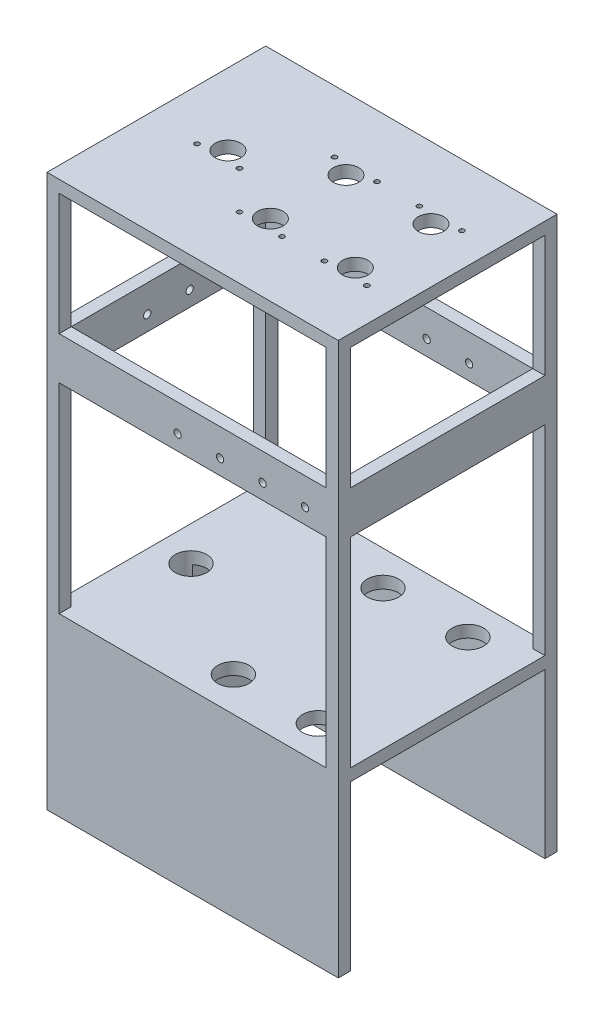
from build123d import *

# Parameters (mm, degrees)
SKETCH1_W           = 240.15
SKETCH1_H           = 180.3
BOSS_EXTRUDE1_DEPTH = 145
SKETCH2_R           = 12.955
CUT_EXTRUDE1_DEPTH  = 120
SKETCH3_W           = 160.42
SKETCH3_H           = 135.06
CUT_EXTRUDE3_DEPTH  = 220
SKETCH9_W           = 240.15
SKETCH9_H           = 180.3
BOSS_EXTRUDE3_DEPTH = 310.134
SKETCH14_R          = 10.5
SKETCH14_R_2        = 2
CUT_EXTRUDE6_DEPTH  = 11
SKETCH15_W          = 220.15
SKETCH15_H          = 100.24
SKETCH15_H_2        = 164.844
CUT_EXTRUDE7_DEPTH  = 181.3
SKETCH16_W          = 160.3
SKETCH16_H          = 100.24
SKETCH16_H_2        = 164.842
CUT_EXTRUDE8_DEPTH  = 241.15
CUT_EXTRUDE9_REACH  = 346.894
SKETCH17_W          = 220.15
SKETCH17_H          = 160.3
SKETCH18_R          = 3
CUT_EXTRUDE10_DEPTH = 249
SKETCH19_R          = 3
CUT_EXTRUDE11_DEPTH = 104


with BuildPart() as part:
    # Sketch1 → Boss-Extrude1 (new body)
    with BuildSketch(Plane(origin=(0, 0, 0), x_dir=(1, 0, 0), z_dir=(0, 1, 0))):
        Rectangle(SKETCH1_W, SKETCH1_H)
    extrude(amount=BOSS_EXTRUDE1_DEPTH)

    # Sketch2 → Cut-Extrude1 (cut)
    with BuildSketch(Plane(origin=(0, 145, 0), x_dir=(1, 0, 0), z_dir=(0, 1, 0))):
        with Locations((75.105, -61.65)):
            Circle(SKETCH2_R)
        with Locations((5.105, -61.65)):
            Circle(SKETCH2_R)
        with Locations((75.105, 61.65)):
            Circle(SKETCH2_R)
        with Locations((5.105, 61.65)):
            Circle(SKETCH2_R)
        with Locations((-91.515, 0)):
            Circle(SKETCH2_R)
    extrude(amount=-CUT_EXTRUDE1_DEPTH, mode=Mode.SUBTRACT)

    # Sketch3 → Cut-Extrude3 (cut)
    with BuildSketch(Plane(origin=(120.075, 0, 0), x_dir=(0, 0, -1), z_dir=(1, 0, 0))):
        with Locations((0, 67.53)):
            Rectangle(SKETCH3_W, SKETCH3_H)
    extrude(amount=-CUT_EXTRUDE3_DEPTH, mode=Mode.SUBTRACT)

    # Sketch9 → Boss-Extrude3 (add)
    with BuildSketch(Plane(origin=(0, 145, 0), x_dir=(1, 0, 0), z_dir=(0, 1, 0))):
        Rectangle(SKETCH9_W, SKETCH9_H)
    extrude(amount=BOSS_EXTRUDE3_DEPTH)

    # Sketch14 → Cut-Extrude6 (cut)
    with BuildSketch(Plane(origin=(0, 455.134, 0), x_dir=(1, 0, 0), z_dir=(0, 1, 0))):
        with Locations((5.105, -31.17)):
            Circle(SKETCH14_R)
        with Locations((75.105, 31.17)):
            Circle(SKETCH14_R)
        with Locations((-61.035, 0)):
            Circle(SKETCH14_R)
        with Locations((75.105, -31.17)):
            Circle(SKETCH14_R)
        with Locations((92.605, -39.14)):
            Circle(SKETCH14_R_2)
        with Locations((57.605, -39.14)):
            Circle(SKETCH14_R_2)
        with Locations((5.105, 31.17)):
            Circle(SKETCH14_R)
        with Locations((92.605, 39.14)):
            Circle(SKETCH14_R_2)
        with Locations((57.605, 39.14)):
            Circle(SKETCH14_R_2)
        with Locations((22.605, -39.14)):
            Circle(SKETCH14_R_2)
        with Locations((-12.395, -39.14)):
            Circle(SKETCH14_R_2)
        with Locations((22.605, 39.14)):
            Circle(SKETCH14_R_2)
        with Locations((-12.395, 39.14)):
            Circle(SKETCH14_R_2)
        with Locations((-43.535, -7.97)):
            Circle(SKETCH14_R_2)
        with Locations((-78.535, -7.97)):
            Circle(SKETCH14_R_2)
    extrude(amount=-CUT_EXTRUDE6_DEPTH, mode=Mode.SUBTRACT)

    # Sketch15 → Cut-Extrude7 (cut, through all)
    with BuildSketch(Plane(origin=(0, 0, -90.15), x_dir=(-1, 0, 0), z_dir=(0, 0, -1))):
        with Locations((0, 395.014)):
            Rectangle(SKETCH15_W, SKETCH15_H)
        with Locations((0, 227.422)):
            Rectangle(SKETCH15_W, SKETCH15_H_2)
    extrude(amount=-CUT_EXTRUDE7_DEPTH, mode=Mode.SUBTRACT)

    # Sketch16 → Cut-Extrude8 (cut, through all)
    with BuildSketch(Plane(origin=(120.075, 0, 0), x_dir=(0, 0, -1), z_dir=(1, 0, 0))):
        with Locations((0, 395.014)):
            Rectangle(SKETCH16_W, SKETCH16_H)
        with Locations((0, 227.421)):
            Rectangle(SKETCH16_W, SKETCH16_H_2)
    extrude(amount=-CUT_EXTRUDE8_DEPTH, mode=Mode.SUBTRACT)

    # Sketch17 → Cut-Extrude9 (cut, up to next)
    with BuildSketch(Plane(origin=(0, 344.894, 0), x_dir=(1, 0, 0), z_dir=(0, 1, 0)), mode=Mode.PRIVATE) as cut_extrude9_sk1:
        Rectangle(SKETCH17_W, SKETCH17_H)
    cut_extrude9_tool1 = extrude(cut_extrude9_sk1.sketch, amount=-CUT_EXTRUDE9_REACH, mode=Mode.PRIVATE) & part.part
    add(cut_extrude9_tool1.solids().sort_by_distance((0, 344.894, 0))[0], mode=Mode.SUBTRACT)

    # Sketch18 → Cut-Extrude10 (cut)
    with BuildSketch(Plane.XY.offset(90.15)):
        with Locations((-12.395, 322.394)):
            Circle(SKETCH18_R)
        with Locations((22.605, 322.394)):
            Circle(SKETCH18_R)
        with Locations((57.605, 322.394)):
            Circle(SKETCH18_R)
        with Locations((92.605, 322.394)):
            Circle(SKETCH18_R)
    extrude(amount=-CUT_EXTRUDE10_DEPTH, mode=Mode.SUBTRACT)

    # Sketch19 → Cut-Extrude11 (cut)
    with BuildSketch(Plane.ZY.offset(120.075)):
        with Locations((-17.5, 322.392)):
            Circle(SKETCH19_R)
        with Locations((17.5, 322.392)):
            Circle(SKETCH19_R)
    extrude(amount=-CUT_EXTRUDE11_DEPTH, mode=Mode.SUBTRACT)


solid = part.part
